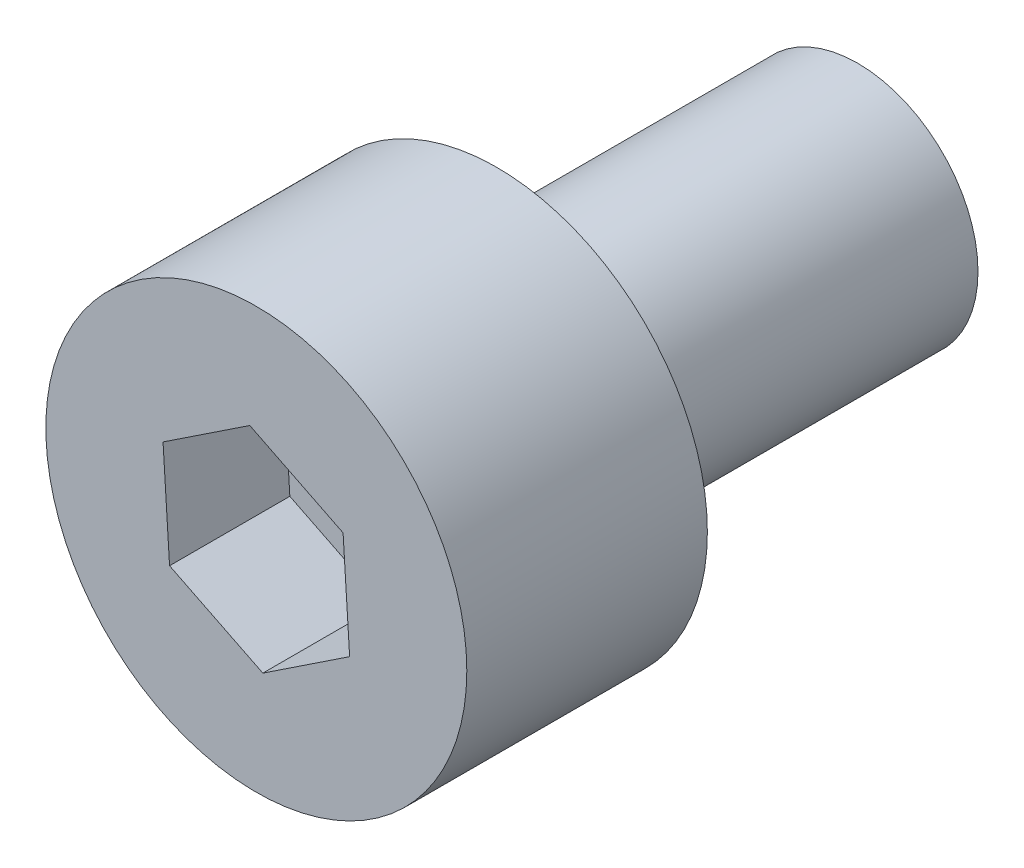
from build123d import *

# Parameters (mm, degrees)
SKETCH_1_R          = 3.5
EXTRUDE_1_DEPTH     = 4
CUT_EXTRUDE_1_DEPTH = 2
SKETCH_3_R          = 2
EXTRUDE_2_DEPTH     = 6


with BuildPart() as part:
    # 草图1 → 凸台-拉伸1 (new body)
    with BuildSketch(Plane.XY):
        Circle(SKETCH_1_R)
    extrude(amount=EXTRUDE_1_DEPTH)

    # 草图2 → 切除-拉伸1 (cut)
    with BuildSketch(Plane.XY.offset(4)):
        Polygon((1.551335969, -0.77029651), (1.44276433, 0.958348104), (-0.108571638, 1.728644613), (-1.551335969, 0.77029651), (-1.44276433, -0.958348104), (0.108571638, -1.728644613), align=None)
    extrude(amount=-CUT_EXTRUDE_1_DEPTH, mode=Mode.SUBTRACT)

    # 草图3 → 凸台-拉伸2 (add)
    with BuildSketch(Plane(origin=(0, 0, 0), x_dir=(-1, 0, 0), z_dir=(0, 0, -1))):
        Circle(SKETCH_3_R)
    extrude(amount=EXTRUDE_2_DEPTH)


solid = part.part
